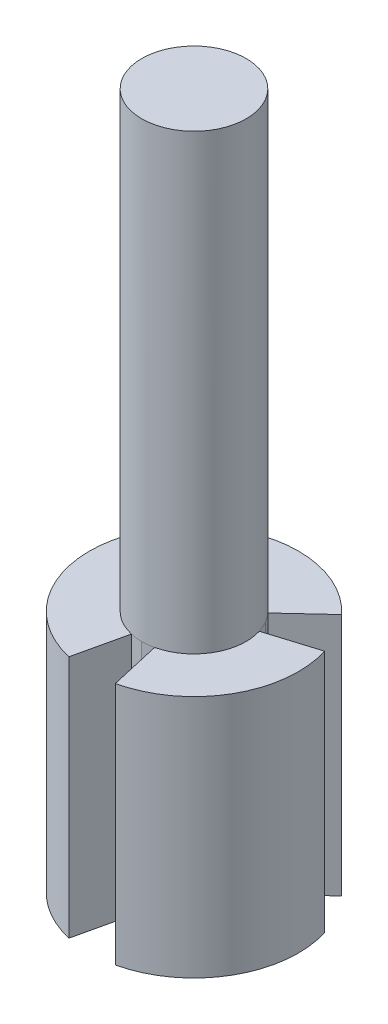
from build123d import *

# Parameters (mm, degrees)
SKETCH1_R           = 15
BOSS_EXTRUDE1_DEPTH = 200
SKETCH2_R           = 30
SKETCH2_R_2         = 15
BOSS_EXTRUDE2_DEPTH = 70
CUT_EXTRUDE1_DEPTH  = 84
CIRPATTERN2_COUNT   = 3


with BuildPart() as part:
    # Sketch1 → Boss-Extrude1 (new body)
    with BuildSketch(Plane(origin=(0, 0, 0), x_dir=(1, 0, 0), z_dir=(0, 1, 0))):
        Circle(SKETCH1_R)
    extrude(amount=BOSS_EXTRUDE1_DEPTH)

    # Sketch2 → Boss-Extrude2 (add)
    with BuildSketch(Plane.XZ):
        Circle(SKETCH2_R)
        Circle(SKETCH2_R_2, mode=Mode.SUBTRACT)
    extrude(amount=-BOSS_EXTRUDE2_DEPTH)

    # Sketch3 → Cut-Extrude1 (cut)
    with BuildSketch(Plane(origin=(0, 70, 0), x_dir=(1, 0, 0), z_dir=(0, 1, 0))):
        Polygon((-3.333611713, -14.624877194), (-7.415359219, -32.531898508), (7.415359219, -32.531898508), (3.333611713, -14.624877194), (0, -15), align=None)
    cut_extrude1 = extrude(amount=-CUT_EXTRUDE1_DEPTH, mode=Mode.SUBTRACT)

    # CirPattern2: Cut-Extrude1 ×3 about axis
    cirpattern2_axis = Axis((0, 0, 0), (0, 1, 0))
    for i in range(1, CIRPATTERN2_COUNT):
        add(cut_extrude1.rotate(cirpattern2_axis, i * 360 / CIRPATTERN2_COUNT), mode=Mode.SUBTRACT)


solid = part.part
